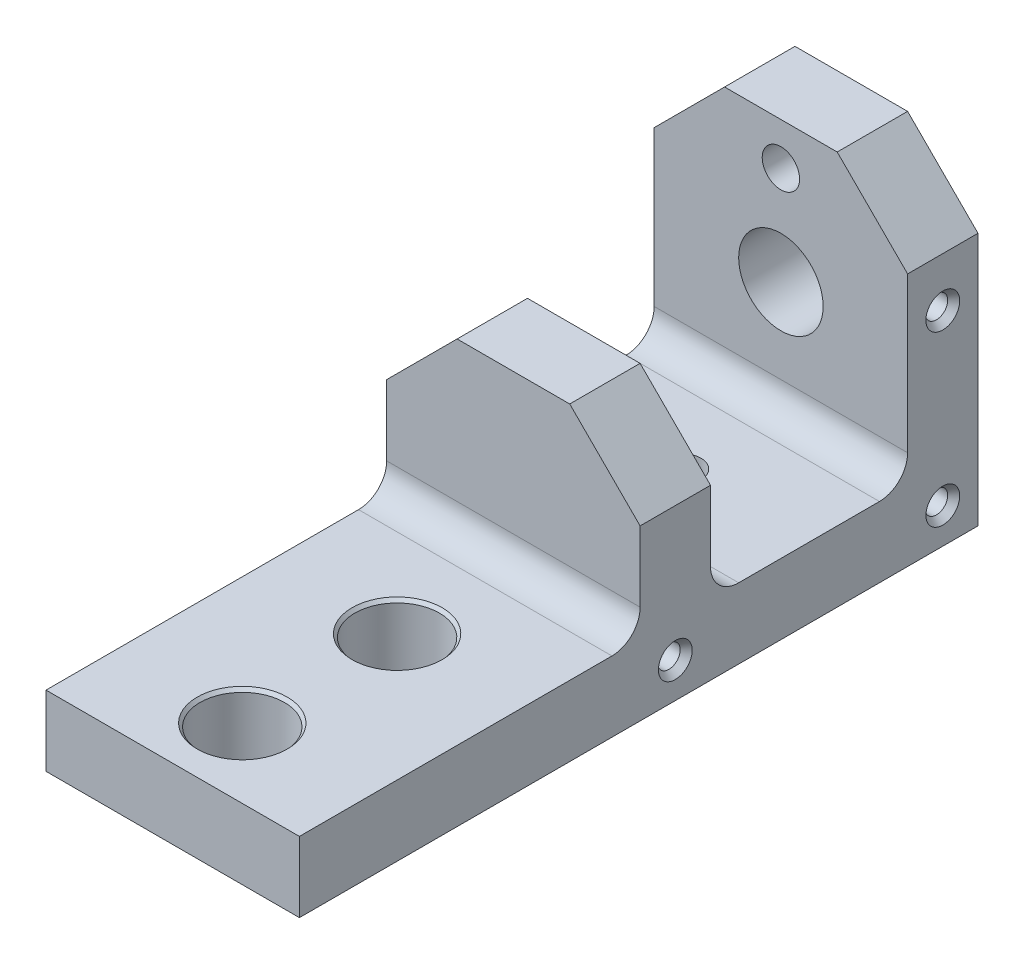
from build123d import *

# Parameters (mm, degrees)
EXTRUDE4_DEPTH                    = 57.15
EXTRUDE7_DEPTH                    = 57.15
CUT_EXTRUDE2_REACH                = 155.035
SKETCH10_R                        = 9.525
F_3_8_24_TAPPED_HOLE1_D           = 8.4328
F_3_8_24_TAPPED_HOLE1_DEPTH       = 15.875
F_3_8_24_TAPPED_HOLE1_CSINK_D     = 10.795
F_3_8_24_TAPPED_HOLE1_CSINK_ANGLE = 82
F_3_8_24_TAPPED_HOLE2_D           = 8.4328
F_3_8_24_TAPPED_HOLE2_DEPTH       = 15.875
F_3_8_24_TAPPED_HOLE2_CSINK_D     = 10.795
F_3_8_24_TAPPED_HOLE2_CSINK_ANGLE = 82
F_1_4_20_TAPPED_HOLE1_D           = 5.1054
F_1_4_20_TAPPED_HOLE1_DEPTH       = 16.51
F_1_4_20_TAPPED_HOLE1_CSINK_D     = 7.62
F_1_4_20_TAPPED_HOLE1_CSINK_ANGLE = 82
F_1_4_20_TAPPED_HOLE1_TIP         = 1.533816902
F_1_4_20_TAPPED_HOLE2_D           = 5.1054
F_1_4_20_TAPPED_HOLE2_DEPTH       = 16.51
F_1_4_20_TAPPED_HOLE2_CSINK_D     = 7.62
F_1_4_20_TAPPED_HOLE2_CSINK_ANGLE = 82
F_1_4_20_TAPPED_HOLE2_TIP         = 1.533816902
CUT_EXTRUDE3_REACH                = 155.035
F_1_2_CLEARANCE_HOLE1_AT_2_COUNT  = 2
F_1_2_CLEARANCE_HOLE1_AT_2_PITCH  = 34.925
CUT_EXTRUDE4_REACH                = 78.2
FILLET4_R                         = 6.35


with BuildPart() as part:
    # Sketch5 → Extrude4 (new body)
    with BuildSketch(Plane(origin=(0, 0, 0), x_dir=(0, 0, -1), z_dir=(1, 0, 0))):
        Polygon((0, 46.0375), (0, -7.9375), (-92.71, -7.9375), (-92.71, 7.9375), (-15.875, 7.9375), (-15.875, 46.0375), align=None)
    extrude(amount=EXTRUDE4_DEPTH)

    # Sketch9 → Extrude7 (add)
    with BuildSketch(Plane(origin=(57.15, 0, 0), x_dir=(0, 0, -1), z_dir=(1, 0, 0))):
        Polygon((0, 7.9375), (44.45, 7.9375), (44.45, 65.0875), (60.325, 65.0875), (60.325, -7.9375), (0, -7.9375), align=None)
    extrude(amount=-EXTRUDE7_DEPTH)

    # Sketch10 → Cut-Extrude2 (cut, up to next)
    with BuildSketch(Plane(origin=(0, 0, -60.325), x_dir=(-1, 0, 0), z_dir=(0, 0, -1)), mode=Mode.PRIVATE) as cut_extrude2_sk1:
        with Locations((-28.575, 33.3375)):
            Circle(SKETCH10_R)
    cut_extrude2_tool1 = extrude(cut_extrude2_sk1.sketch, amount=-CUT_EXTRUDE2_REACH, mode=Mode.PRIVATE) & part.part
    add(cut_extrude2_tool1.solids().sort_by_distance((28.575, 33.3375, -60.325))[0], mode=Mode.SUBTRACT)

    # 3/8-24 Tapped Hole1
    with Locations(Plane(origin=(0, 0, -60.325), x_dir=(-1, 0, 0), z_dir=(0, 0, -1))):
        with Locations((-28.575, 55.5625)):
            CounterSinkHole(F_3_8_24_TAPPED_HOLE1_D / 2, F_3_8_24_TAPPED_HOLE1_CSINK_D / 2, depth=F_3_8_24_TAPPED_HOLE1_DEPTH, counter_sink_angle=F_3_8_24_TAPPED_HOLE1_CSINK_ANGLE)

    # 3/8-24 Tapped Hole2
    with Locations(Plane.XZ.offset(7.9375)):
        with Locations((28.575, -22.225)):
            CounterSinkHole(F_3_8_24_TAPPED_HOLE2_D / 2, F_3_8_24_TAPPED_HOLE2_CSINK_D / 2, depth=F_3_8_24_TAPPED_HOLE2_DEPTH, counter_sink_angle=F_3_8_24_TAPPED_HOLE2_CSINK_ANGLE)

    # 1/4-20 Tapped Hole1
    with Locations(Plane.ZY):
        with Locations((-52.3875, 0), (7.9375, 0), (-52.3875, 38.1)):
            CounterSinkHole(F_1_4_20_TAPPED_HOLE1_D / 2, F_1_4_20_TAPPED_HOLE1_CSINK_D / 2, depth=F_1_4_20_TAPPED_HOLE1_DEPTH, counter_sink_angle=F_1_4_20_TAPPED_HOLE1_CSINK_ANGLE)
            with Locations((0, 0, -(F_1_4_20_TAPPED_HOLE1_DEPTH + F_1_4_20_TAPPED_HOLE1_TIP / 2))):  # 118° drill point
                Cone(0, F_1_4_20_TAPPED_HOLE1_D / 2, F_1_4_20_TAPPED_HOLE1_TIP, mode=Mode.SUBTRACT)

    # 1/4-20 Tapped Hole2
    with Locations(Plane(origin=(57.15, 0, 0), x_dir=(0, 0, -1), z_dir=(1, 0, 0))):
        with Locations((52.3875, 0), (-7.9375, 0), (52.3875, 38.1)):
            CounterSinkHole(F_1_4_20_TAPPED_HOLE2_D / 2, F_1_4_20_TAPPED_HOLE2_CSINK_D / 2, depth=F_1_4_20_TAPPED_HOLE2_DEPTH, counter_sink_angle=F_1_4_20_TAPPED_HOLE2_CSINK_ANGLE)
            with Locations((0, 0, -(F_1_4_20_TAPPED_HOLE2_DEPTH + F_1_4_20_TAPPED_HOLE2_TIP / 2))):  # 118° drill point
                Cone(0, F_1_4_20_TAPPED_HOLE2_D / 2, F_1_4_20_TAPPED_HOLE2_TIP, mode=Mode.SUBTRACT)

    # Sketch19 → Cut-Extrude3 (cut, up to next)
    with BuildSketch(Plane(origin=(0, 0, -60.325), x_dir=(-1, 0, 0), z_dir=(0, 0, -1)), mode=Mode.PRIVATE) as cut_extrude3_sk1:
        Polygon((-57.15, 49.2125), (-41.275, 65.0875), (-57.15, 65.0875), align=None)
    cut_extrude3_tool1 = extrude(cut_extrude3_sk1.sketch, amount=-CUT_EXTRUDE3_REACH, mode=Mode.PRIVATE) & part.part
    add(cut_extrude3_tool1.solids().sort_by_distance((51.858333, 59.795833, -60.325))[0], mode=Mode.SUBTRACT)
    # Sketch19 → Cut-Extrude3 (cut, up to next)
    with BuildSketch(Plane(origin=(0, 0, -60.325), x_dir=(-1, 0, 0), z_dir=(0, 0, -1)), mode=Mode.PRIVATE) as cut_extrude3_sk2:
        Polygon((0, 49.2125), (0, 65.0875), (-15.875, 65.0875), align=None)
    cut_extrude3_tool2 = extrude(cut_extrude3_sk2.sketch, amount=-CUT_EXTRUDE3_REACH, mode=Mode.PRIVATE) & part.part
    add(cut_extrude3_tool2.solids().sort_by_distance((5.291667, 59.795833, -60.325))[0], mode=Mode.SUBTRACT)

    # Sketch22 → 1/2 Clearance Hole1 (revolve, cut)
    with BuildSketch(Plane(origin=(28.575, -7.9375, 77.0255), x_dir=(0, 0, -1), z_dir=(1, 0, 0))):
        Polygon((0, 0), (0, 15.875), (10.16, 15.875), (9.525, 15.144516061), (9.525, 0.730483939), (10.16, 0), align=None)
    f_1_2_clearance_hole1 = revolve(axis=Axis((28.575, -14.2875, 77.0255), (0, 1, 0)), mode=Mode.SUBTRACT)

    # 1/2 Clearance Hole1 at 2: 1/2 Clearance Hole1 ×2
    with Locations(*[(0, 0, -i * F_1_2_CLEARANCE_HOLE1_AT_2_PITCH) for i in range(1, F_1_2_CLEARANCE_HOLE1_AT_2_COUNT)]):
        add(f_1_2_clearance_hole1, mode=Mode.SUBTRACT)

    # Sketch24 → Cut-Extrude4 (cut, up to next)
    with BuildSketch(Plane.XY.offset(15.875), mode=Mode.PRIVATE) as cut_extrude4_sk1:
        Polygon((0, 30.1625), (15.875, 46.0375), (0, 46.0375), align=None)
    cut_extrude4_tool1 = extrude(cut_extrude4_sk1.sketch, amount=-CUT_EXTRUDE4_REACH, mode=Mode.PRIVATE) & part.part
    add(cut_extrude4_tool1.solids().sort_by_distance((5.291667, 40.745833, 15.875))[0], mode=Mode.SUBTRACT)
    # Sketch24 → Cut-Extrude4 (cut, up to next)
    with BuildSketch(Plane.XY.offset(15.875), mode=Mode.PRIVATE) as cut_extrude4_sk2:
        Polygon((57.15, 30.1625), (57.15, 46.0375), (41.275, 46.0375), align=None)
    cut_extrude4_tool2 = extrude(cut_extrude4_sk2.sketch, amount=-CUT_EXTRUDE4_REACH, mode=Mode.PRIVATE) & part.part
    add(cut_extrude4_tool2.solids().sort_by_distance((51.858333, 40.745833, 15.875))[0], mode=Mode.SUBTRACT)

    # Fillet4
    fillet4_edges = [part.edges().sort_by_distance(p)[0] for p in [
        (28.575, 7.9375, 0),
        (28.575, 7.9375, -44.45),
        (28.575, 7.9375, 15.875),
    ]]
    fillet(fillet4_edges, radius=FILLET4_R)


solid = part.part
